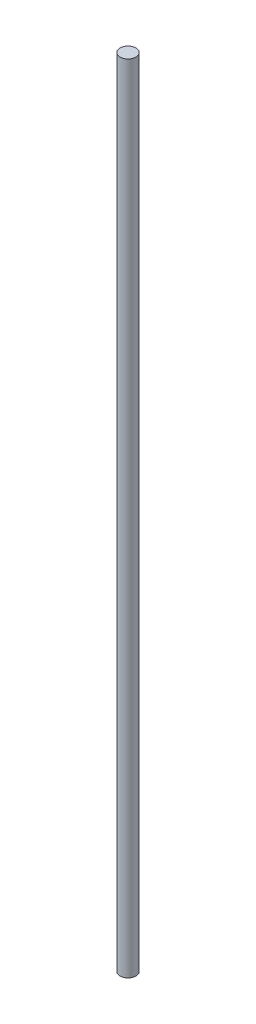
from build123d import *

# Parameters (mm, degrees)
SKETCH1_R           = 4
BOSS_EXTRUDE1_DEPTH = 400


with BuildPart() as part:
    # Sketch1 → Boss-Extrude1 (new body)
    with BuildSketch(Plane(origin=(0, 0, 0), x_dir=(1, 0, 0), z_dir=(0, 1, 0))):
        with Locations((-18.443963112, 5.193989612)):
            Circle(SKETCH1_R)
    extrude(amount=BOSS_EXTRUDE1_DEPTH)


solid = part.part
